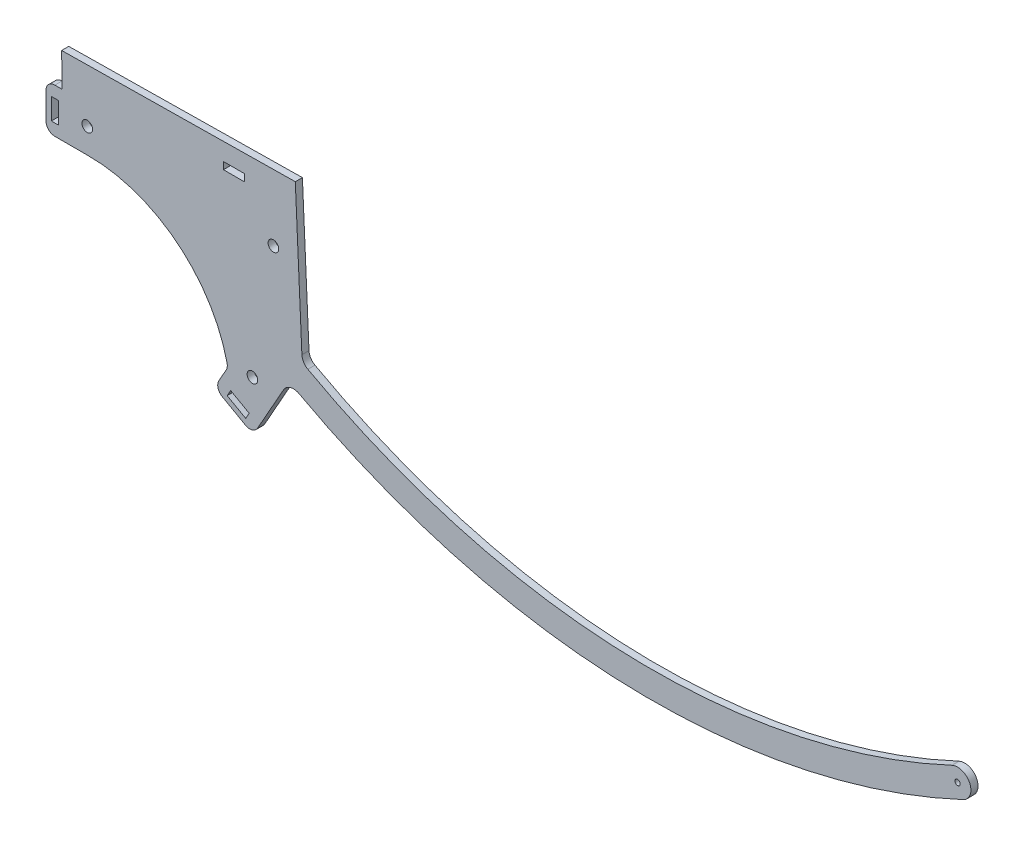
from build123d import *

# Parameters (mm, degrees)
ESQUISSE2_R             = 3
BOSS_EXTRU_1_DEPTH      = 4
ESQUISSE3_R             = 1.5
ENL_V_MAT_EXTRU_1_DEPTH = 5
CONG_1_R                = 6.5
ESQUISSE4_W             = 4
ESQUISSE4_H             = 12
BOSS_EXTRU_2_DEPTH      = 4
CONG_2_R                = 5
ESQUISSE5_W             = 12
ESQUISSE5_H             = 4
ENL_V_MAT_EXTRU_2_DEPTH = 4


with BuildPart() as part:
    # Esquisse2 → Boss.-Extru.1 (new body)
    with BuildSketch(Plane.XY):
        with BuildLine():
            Line((-199.971644797, -262.478940861), (-196.098548459, -348.633560192))
            ThreePointArc((-196.098548459, -348.633560192), (-8.923258694, -399.900456932), (180.352503917, -357.033575915))
            Line((180.352503917, -357.033575915), (187.115722814, -370.422335012))
            ThreePointArc((187.115722814, -370.422335012), (-9.257880895, -414.896724067), (-203.452244027, -361.707318699))
            Line((-203.452244027, -361.707318699), (-211.920441681, -376.762493353))
            ThreePointArc((-211.920441681, -376.762493353), (-226.337772202, -383.722686379), (-237.858405423, -372.606089933))
            ThreePointArc((-237.858405423, -372.606089933), (-265.801404699, -326.067035455), (-317.01741072, -308.077718418))
            ThreePointArc((-317.01741072, -308.077718418), (-326.924525304, -304.085923492), (-331.133147983, -294.268956483))
            Line((-331.133147983, -294.268956483), (-331.541895531, -264.271741188))
            Line((-331.541895531, -264.271741188), (-199.971644797, -262.478940861))
        make_face()
        with Locations((-317.134447512, -294.078207627)):
            Circle(ESQUISSE2_R, mode=Mode.SUBTRACT)
        with Locations((-212.300150205, -299.974825982)):
            Circle(ESQUISSE2_R, mode=Mode.SUBTRACT)
        with Locations((-224.122616287, -369.899044157)):
            Circle(ESQUISSE2_R, mode=Mode.SUBTRACT)
    extrude(amount=BOSS_EXTRU_1_DEPTH)

    # Esquisse3 → Enlèv. mat.-Extru.1 (cut, through all)
    with BuildSketch(Plane.XY.offset(4)):
        with Locations((172.9434239, -368.980788294)):
            Circle(ESQUISSE3_R)
        with BuildLine():
            Line((169.760416098, -362.18973084), (162.877223829, -362.18973084))
            Line((162.877223829, -362.18973084), (180.965097343, -354.152116582))
            Line((180.965097343, -354.152116582), (180.352503917, -357.033575915))
            Line((180.352503917, -357.033575915), (187.115722814, -370.422335012))
            Line((187.115722814, -370.422335012), (190.286834204, -373.47465723))
            Line((190.286834204, -373.47465723), (174.853495029, -378.475059123))
            Line((174.853495029, -378.475059123), (176.126431702, -375.771845747))
            ThreePointArc((176.126431702, -375.771845747), (179.734481353, -365.797780492), (169.760416098, -362.18973084))
        make_face()
    extrude(amount=-ENL_V_MAT_EXTRU_1_DEPTH, mode=Mode.SUBTRACT)

    # Congé1
    cong_1_edges = [part.edges().sort_by_distance(p)[0] for p in [
        (-203.452244027, -361.707318699, 2),
        (-196.098548459, -348.633560192, 2),
    ]]
    fillet(cong_1_edges, radius=CONG_1_R)

    # Esquisse4 → Boss.-Extru.2 (add)
    with BuildSketch(Plane.XY.offset(4)):
        Polygon((-211.920441681, -376.762493353), (-223.686354588, -397.680506965), (-245.4759521, -385.424347686), (-237.96555462, -372.071996878), (-225.374330656, -376.762493353), align=None)
        Polygon((-238.339917634, -385.996197397), (-227.880910828, -391.879153851), (-225.919925343, -388.392818249), (-236.378932149, -382.509861795), align=None, mode=Mode.SUBTRACT)
        Polygon((-316.348629052, -308.074922938), (-340.348629052, -308.074922938), (-340.348629052, -283.074922938), (-331.285679934, -283.074922938), align=None)
        with Locations((-335.348629052, -295.574922938)):
            Rectangle(ESQUISSE4_W, ESQUISSE4_H, mode=Mode.SUBTRACT)
    extrude(amount=-BOSS_EXTRU_2_DEPTH)

    # Congé2
    cong_2_edges = [part.edges().sort_by_distance(p)[0] for p in [
        (-340.348629052, -308.074922938, 2),
        (-340.348629052, -283.074922938, 2),
        (-223.686354588, -397.680506965, 2),
        (-245.4759521, -385.424347686, 2),
        (-237.96555462, -372.071996878, 2),
    ]]
    fillet(cong_2_edges, radius=CONG_2_R)

    # Esquisse5 → Enlèv. mat.-Extru.2 (cut)
    with BuildSketch(Plane.XY.offset(4)):
        with Locations((-234.450045065, -274.867921079)):
            Rectangle(ESQUISSE5_W, ESQUISSE5_H)
    extrude(amount=-ENL_V_MAT_EXTRU_2_DEPTH, mode=Mode.SUBTRACT)


solid = part.part
